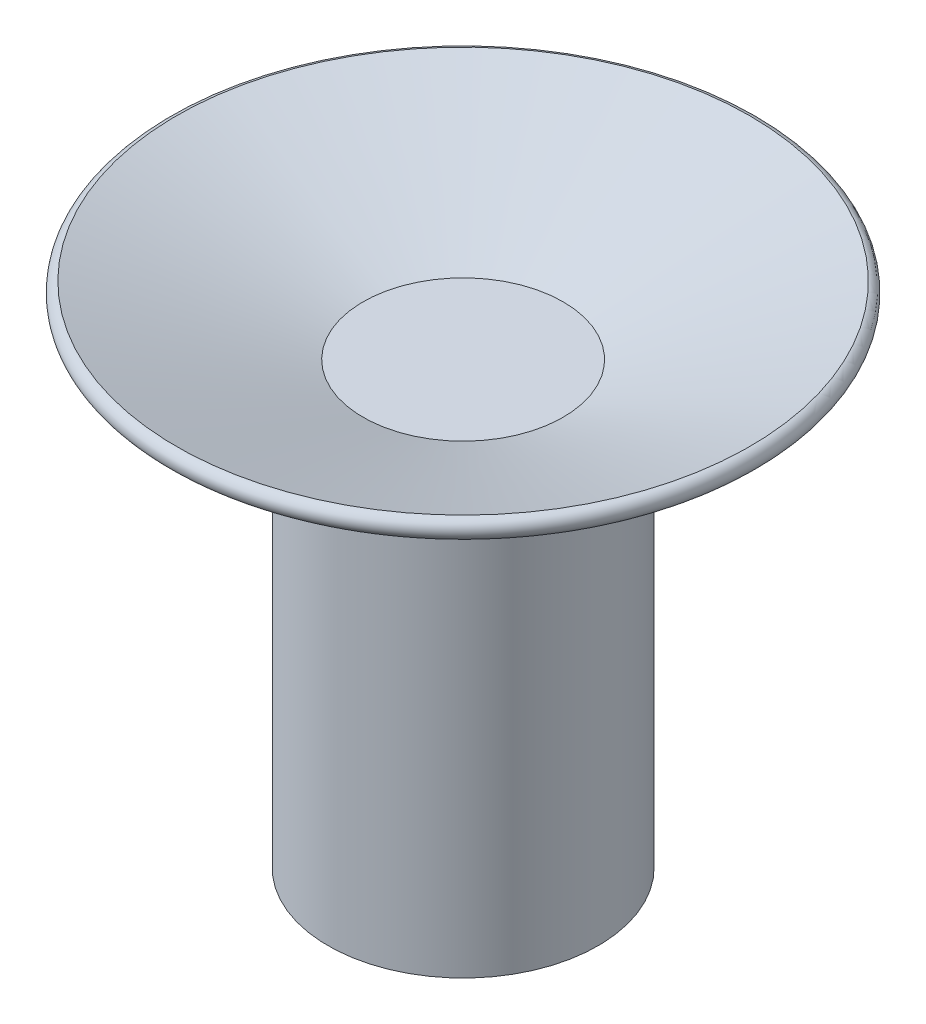
from build123d import *

# Parameters (mm, degrees)
BOSS_EXTRU_1_DEPTH  = 1
SKETCH1_R           = 6.75
BOSS_EXTRUDE1_DEPTH = 20


with BuildPart() as part:
    # Esquisse1 → Révolution1 (revolve)
    with BuildSketch(Plane.XY):
        with BuildLine():
            Line((0, 0), (5, 0))
            Line((5, 0), (14.396926208, 3.420201433))
            ThreePointArc((14.396926208, 3.420201433), (14.728803197, 3.934870166), (14.322587886, 4.393144497))
            Line((14.322587886, 4.393144497), (5, 1))
            Line((5, 1), (0, 1))
            Line((0, 1), (0, 0))
        make_face()
    revolve(axis=Axis((0, 0, 0), (0, 1, 0)))

    # Esquisse2 → Boss.-Extru.1 (add)
    with BuildSketch(Plane.XZ):
        Polygon((2.792425312, -4.14757289), (4.988116143, 0.344524813), (2.195690831, 4.492097703), (-2.792425312, 4.14757289), (-4.988116143, -0.344524813), (-2.195690831, -4.492097703), align=None)
    extrude(amount=BOSS_EXTRU_1_DEPTH)

    # Sketch1 → Boss-Extrude1 (add)
    with BuildSketch(Plane.XZ.offset(1)):
        Circle(SKETCH1_R)
    extrude(amount=BOSS_EXTRUDE1_DEPTH)


solid = part.part
